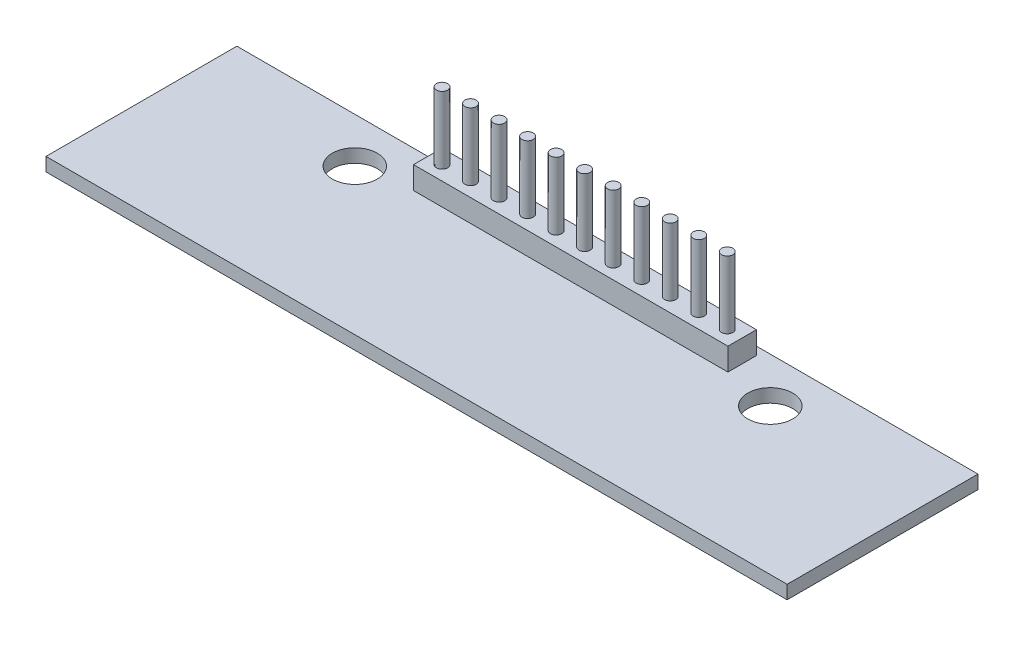
from build123d import *

# Parameters (mm, degrees)
SKETCH1_W           = 66
SKETCH1_H           = 17
SKETCH1_R           = 2
BOSS_EXTRUDE1_DEPTH = 1.2
SKETCH2_W           = 28
SKETCH2_H           = 2.54
BOSS_EXTRUDE2_DEPTH = 2
SKETCH3_R           = 0.5
BOSS_EXTRUDE3_DEPTH = 6


with BuildPart() as part:
    # Sketch1 → Boss-Extrude1 (new body)
    with BuildSketch(Plane(origin=(0, 0, 0), x_dir=(1, 0, 0), z_dir=(0, 1, 0))):
        Rectangle(SKETCH1_W, SKETCH1_H)
        with Locations((18.5, 4.5)):
            Circle(SKETCH1_R, mode=Mode.SUBTRACT)
        with Locations((-18.5, 4.5)):
            Circle(SKETCH1_R, mode=Mode.SUBTRACT)
    extrude(amount=BOSS_EXTRUDE1_DEPTH)

    # Sketch2 → Boss-Extrude2 (add)
    with BuildSketch(Plane(origin=(0, 1.2, 0), x_dir=(1, 0, 0), z_dir=(0, 1, 0))):
        with Locations((0, 6.5)):
            Rectangle(SKETCH2_W, SKETCH2_H)
    extrude(amount=BOSS_EXTRUDE2_DEPTH)

    # Sketch3 → Boss-Extrude3 (add)
    with BuildSketch(Plane(origin=(0, 3.2, 0), x_dir=(1, 0, 0), z_dir=(0, 1, 0))):
        with Locations((-12.73, 6.5)):
            Circle(SKETCH3_R)
        with Locations((-10.19, 6.5)):
            Circle(SKETCH3_R)
        with Locations((-7.65, 6.5)):
            Circle(SKETCH3_R)
        with Locations((-5.11, 6.5)):
            Circle(SKETCH3_R)
        with Locations((-2.57, 6.5)):
            Circle(SKETCH3_R)
        with Locations((-0.03, 6.5)):
            Circle(SKETCH3_R)
        with Locations((2.51, 6.5)):
            Circle(SKETCH3_R)
        with Locations((5.05, 6.5)):
            Circle(SKETCH3_R)
        with Locations((7.59, 6.5)):
            Circle(SKETCH3_R)
        with Locations((10.13, 6.5)):
            Circle(SKETCH3_R)
        with Locations((12.67, 6.5)):
            Circle(SKETCH3_R)
    extrude(amount=BOSS_EXTRUDE3_DEPTH)


solid = part.part
